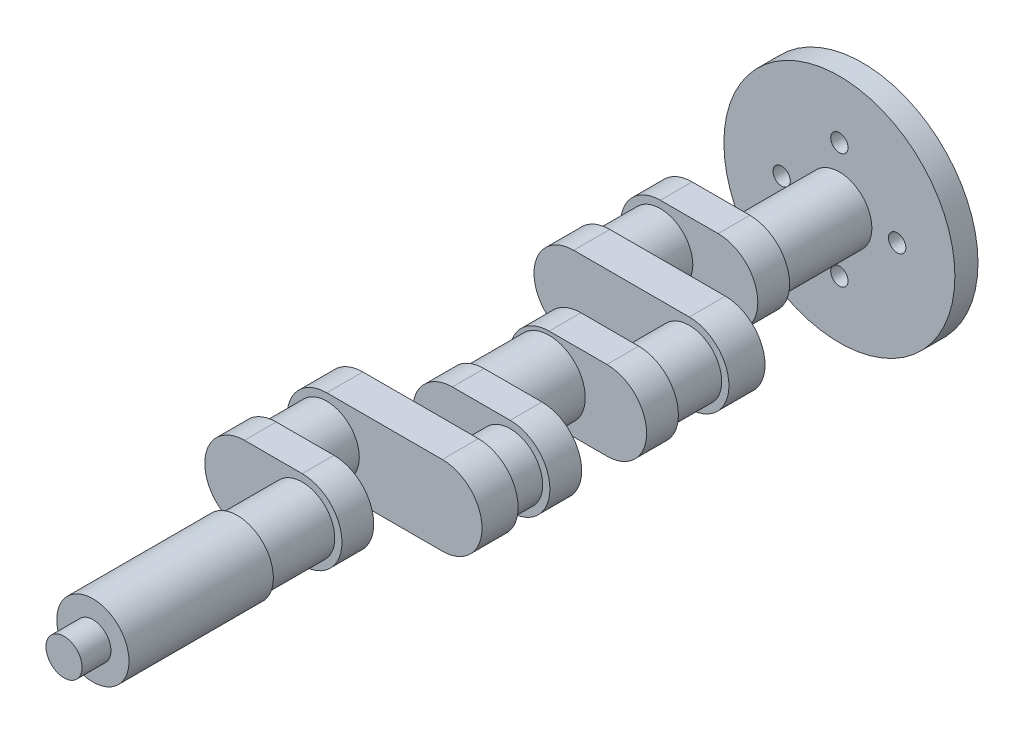
from build123d import *

# Parameters (mm, degrees)
SKETCH1_R            = 80
BOSS_EXTRUDE1_DEPTH  = 16
SKETCH2_R            = 22.5
BOSS_EXTRUDE2_DEPTH  = 62
BOSS_EXTRUDE3_DEPTH  = 22
SKETCH4_R            = 22.5
BOSS_EXTRUDE4_DEPTH  = 35
BOSS_EXTRUDE5_DEPTH  = 25
SKETCH6_R            = 22.5
BOSS_EXTRUDE6_DEPTH  = 35
BOSS_EXTRUDE7_DEPTH  = 22
SKETCH8_R            = 25
BOSS_EXTRUDE8_DEPTH  = 45
BOSS_EXTRUDE9_DEPTH  = 22
SKETCH10_R           = 22.5
BOSS_EXTRUDE10_DEPTH = 22
BOSS_EXTRUDE11_DEPTH = 25
SKETCH12_R           = 22.5
BOSS_EXTRUDE12_DEPTH = 35
BOSS_EXTRUDE13_DEPTH = 22
SKETCH14_R           = 22.5
BOSS_EXTRUDE14_DEPTH = 45
SKETCH15_R           = 25
BOSS_EXTRUDE15_DEPTH = 100
SKETCH16_R           = 12.5
BOSS_EXTRUDE16_DEPTH = 20
SKETCH17_R           = 6
CUT_EXTRUDE1_DEPTH   = 16
CIRPATTERN1_COUNT    = 4


with BuildPart() as part:
    # Sketch1 → Boss-Extrude1 (new body)
    with BuildSketch(Plane.XY):
        Circle(SKETCH1_R)
    extrude(amount=BOSS_EXTRUDE1_DEPTH)

    # Sketch2 → Boss-Extrude2 (add)
    with BuildSketch(Plane.XY.offset(16)):
        Circle(SKETCH2_R)
    extrude(amount=BOSS_EXTRUDE2_DEPTH)

    # Sketch3 → Boss-Extrude3 (add)
    with BuildSketch(Plane.XY.offset(78)):
        with BuildLine():
            Line((0, -27.5), (-40, -27.5))
            ThreePointArc((-40, -27.5), (-67.5, 0), (-40, 27.5))
            Line((-40, 27.5), (0, 27.5))
            ThreePointArc((0, 27.5), (27.5, 0), (0, -27.5))
        make_face()
    extrude(amount=BOSS_EXTRUDE3_DEPTH)

    # Sketch4 → Boss-Extrude4 (add)
    with BuildSketch(Plane.XY.offset(100)):
        with Locations((-40, 0)):
            Circle(SKETCH4_R)
    extrude(amount=BOSS_EXTRUDE4_DEPTH)

    # Sketch5 → Boss-Extrude5 (add)
    with BuildSketch(Plane.XY.offset(135)):
        with BuildLine():
            Line((-40, 27.5), (40, 27.5))
            ThreePointArc((40, 27.5), (67.5, 0), (40, -27.5))
            Line((40, -27.5), (-40, -27.5))
            ThreePointArc((-40, -27.5), (-67.5, 0), (-40, 27.5))
        make_face()
    extrude(amount=BOSS_EXTRUDE5_DEPTH)

    # Sketch6 → Boss-Extrude6 (add)
    with BuildSketch(Plane.XY.offset(160)):
        with Locations((40, 0)):
            Circle(SKETCH6_R)
    extrude(amount=BOSS_EXTRUDE6_DEPTH)

    # Sketch7 → Boss-Extrude7 (add)
    with BuildSketch(Plane.XY.offset(195)):
        with BuildLine():
            Line((40, -27.5), (0, -27.5))
            ThreePointArc((0, -27.5), (-27.5, 0), (0, 27.5))
            Line((0, 27.5), (40, 27.5))
            ThreePointArc((40, 27.5), (67.5, 0), (40, -27.5))
        make_face()
    extrude(amount=BOSS_EXTRUDE7_DEPTH)

    # Sketch8 → Boss-Extrude8 (add)
    with BuildSketch(Plane.XY.offset(217)):
        Circle(SKETCH8_R)
    extrude(amount=BOSS_EXTRUDE8_DEPTH)

    # Sketch9 → Boss-Extrude9 (add)
    with BuildSketch(Plane.XY.offset(262)):
        with BuildLine():
            Line((40, 27.5), (0, 27.5))
            ThreePointArc((0, 27.5), (-27.5, 0), (0, -27.5))
            Line((0, -27.5), (40, -27.5))
            ThreePointArc((40, -27.5), (67.5, 0), (40, 27.5))
        make_face()
    extrude(amount=BOSS_EXTRUDE9_DEPTH)

    # Sketch10 → Boss-Extrude10 (add)
    with BuildSketch(Plane.XY.offset(284)):
        with Locations((40, 0)):
            Circle(SKETCH10_R)
    extrude(amount=BOSS_EXTRUDE10_DEPTH)

    # Sketch11 → Boss-Extrude11 (add)
    with BuildSketch(Plane.XY.offset(306)):
        with BuildLine():
            Line((40, -27.5), (-40, -27.5))
            ThreePointArc((-40, -27.5), (-67.5, 0), (-40, 27.5))
            Line((-40, 27.5), (40, 27.5))
            ThreePointArc((40, 27.5), (67.5, 0), (40, -27.5))
        make_face()
    extrude(amount=BOSS_EXTRUDE11_DEPTH)

    # Sketch12 → Boss-Extrude12 (add)
    with BuildSketch(Plane.XY.offset(331)):
        with Locations((-40, 0)):
            Circle(SKETCH12_R)
    extrude(amount=BOSS_EXTRUDE12_DEPTH)

    # Sketch13 → Boss-Extrude13 (add)
    with BuildSketch(Plane.XY.offset(366)):
        with BuildLine():
            Line((-40, 27.5), (0, 27.5))
            ThreePointArc((0, 27.5), (27.5, 0), (0, -27.5))
            Line((0, -27.5), (-40, -27.5))
            ThreePointArc((-40, -27.5), (-67.5, 0), (-40, 27.5))
        make_face()
    extrude(amount=BOSS_EXTRUDE13_DEPTH)

    # Sketch14 → Boss-Extrude14 (add)
    with BuildSketch(Plane.XY.offset(388)):
        Circle(SKETCH14_R)
    extrude(amount=BOSS_EXTRUDE14_DEPTH)

    # Sketch15 → Boss-Extrude15 (add)
    with BuildSketch(Plane.XY.offset(433)):
        Circle(SKETCH15_R)
    extrude(amount=BOSS_EXTRUDE15_DEPTH)

    # Sketch16 → Boss-Extrude16 (add)
    with BuildSketch(Plane.XY.offset(533)):
        Circle(SKETCH16_R)
    extrude(amount=BOSS_EXTRUDE16_DEPTH)

    # Sketch17 → Cut-Extrude1 (cut)
    with BuildSketch(Plane(origin=(0, 0, 0), x_dir=(-1, 0, 0), z_dir=(0, 0, -1))):
        with Locations((0, 40)):
            Circle(SKETCH17_R)
    cut_extrude1 = extrude(amount=-CUT_EXTRUDE1_DEPTH, mode=Mode.SUBTRACT)

    # CirPattern1: Cut-Extrude1 ×4 about axis
    cirpattern1_axis = Axis((0, 0, 0), (0, 0, 1))
    for i in range(1, CIRPATTERN1_COUNT):
        add(cut_extrude1.rotate(cirpattern1_axis, i * 360 / CIRPATTERN1_COUNT), mode=Mode.SUBTRACT)


solid = part.part
